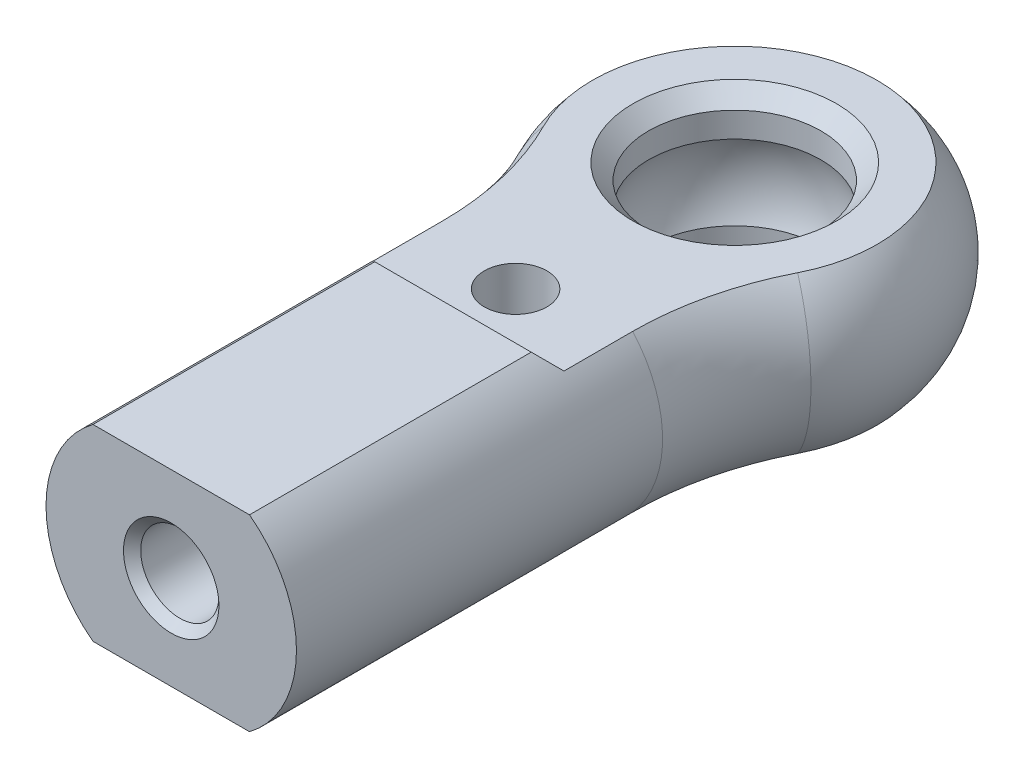
from build123d import *

# Parameters (mm, degrees)
BOSS_EXTRUDE1_DEPTH         = 3
FILLET1_R                   = 10
M3_TAPPED_HOLE1_D           = 2.5
M3_TAPPED_HOLE1_DEPTH       = 5
M3_TAPPED_HOLE1_CSINK_D     = 3.05
M3_TAPPED_HOLE1_CSINK_ANGLE = 90
M3_TAPPED_HOLE1_TIP         = 0.751075774
CUT_EXTRUDE1_DEPTH          = 6.5000001
SKETCH8_R                   = 1
CUT_EXTRUDE2_DEPTH          = 4
CUT_EXTRUDE2_DEPTH_BACK     = 4
CHAMFER1_SIZE               = 0.5


with BuildPart() as part:
    # Sketch1 → Boss-Extrude1 (new body, symmetric)
    with BuildSketch(Plane(origin=(0, 0, 0), x_dir=(1, 0, 0), z_dir=(0, 1, 0))):
        with BuildLine():
            Line((-2.5, -3.122498999), (-2.5, -18))
            Line((-2.5, -18), (2.5, -18))
            Line((2.5, -18), (2.5, -3.122498999))
            ThreePointArc((2.5, -3.122498999), (0, 4), (-2.5, -3.122498999))
        make_face()
    extrude(amount=BOSS_EXTRUDE1_DEPTH, both=True)

    # Fillet1
    fillet1_edges = [part.edges().sort_by_distance(p)[0] for p in [
        (-2.5, 0, 3.122498999),
        (2.5, 0, 3.122498999),
    ]]
    fillet(fillet1_edges, radius=FILLET1_R)

    # Sweep1: sweep along a path in Sketch3
    with BuildLine(Plane(origin=(0, 3, 0), x_dir=(1, 0, 0), z_dir=(0, 1, 0))) as sweep1_path:
        Line((2.5, -18), (2.5, -6.304760106))
        ThreePointArc((2.5, -6.304760106), (2.771543949, -3.990209857), (3.571428571, -1.80136003))
        ThreePointArc((3.571428571, -1.80136003), (0, 4), (-3.571428571, -1.80136003))
        ThreePointArc((-3.571428571, -1.80136003), (-2.771543949, -3.990209857), (-2.5, -6.304760106))
        Line((-2.5, -6.304760106), (-2.5, -18))
    # Sketch2 → Sweep1 (sweep)
    with BuildSketch(Plane.XY.offset(18)):
        with BuildLine():
            Line((2.5, 3), (2.5, -3))
            ThreePointArc((2.5, -3), (4, 0), (2.5, 3))
        make_face()
    sweep(path=sweep1_path.line)

    # M3 Tapped Hole1
    with Locations(Plane.XY.offset(18)):
        with Locations((0, 0)):
            CounterSinkHole(M3_TAPPED_HOLE1_D / 2, M3_TAPPED_HOLE1_CSINK_D / 2, depth=M3_TAPPED_HOLE1_DEPTH, counter_sink_angle=M3_TAPPED_HOLE1_CSINK_ANGLE)
            with Locations((0, 0, -(M3_TAPPED_HOLE1_DEPTH + M3_TAPPED_HOLE1_TIP / 2))):  # 118° drill point
                Cone(0, M3_TAPPED_HOLE1_D / 2, M3_TAPPED_HOLE1_TIP, mode=Mode.SUBTRACT)

    # Sketch6 → Cut-Extrude1 (cut, symmetric)
    with BuildSketch(Plane(origin=(0, 0, 0), x_dir=(0, 0, -1), z_dir=(1, 0, 0))):
        Polygon((-9, 3), (-8.5, 2.5), (11, 2.5), (11, 3), align=None)
    cut_extrude1 = extrude(amount=CUT_EXTRUDE1_DEPTH, both=True, mode=Mode.SUBTRACT)

    # Mirror1: Cut-Extrude1 across plane
    add(cut_extrude1.mirror(Plane.ZX), mode=Mode.SUBTRACT)

    # Sketch7 → Cut-Revolve1 (revolve, cut)
    with BuildSketch(Plane(origin=(0, 0, 0), x_dir=(0, 0, -1), z_dir=(1, 0, 0))):
        with BuildLine():
            Line((0, 3), (0, -3))
            Line((0, -3), (2.75, -3))
            Line((2.75, -3), (2.75, -1.198957881))
            ThreePointArc((2.75, -1.198957881), (3, 0), (2.75, 1.198957881))
            Line((2.75, 1.198957881), (2.75, 3))
            Line((2.75, 3), (0, 3))
        make_face()
    revolve(axis=Axis((0, 6.277574948, 0), (0, -1, 0)), mode=Mode.SUBTRACT)

    # Sketch8 → Cut-Extrude2 (cut, two sides)
    with BuildSketch(Plane(origin=(0, 0, 0), x_dir=(1, 0, 0), z_dir=(0, 1, 0))) as cut_extrude2_sk:
        with Locations((0, -7)):
            Circle(SKETCH8_R)
    extrude(amount=CUT_EXTRUDE2_DEPTH, mode=Mode.SUBTRACT)
    extrude(cut_extrude2_sk.sketch, amount=-CUT_EXTRUDE2_DEPTH_BACK, mode=Mode.SUBTRACT)

    # Chamfer1
    chamfer1_edges = [part.edges().sort_by_distance(p)[0] for p in [
        (0, 2.5, 2.75),
        (0, -2.5, 2.75),
    ]]
    chamfer(chamfer1_edges, length=CHAMFER1_SIZE)


solid = part.part
